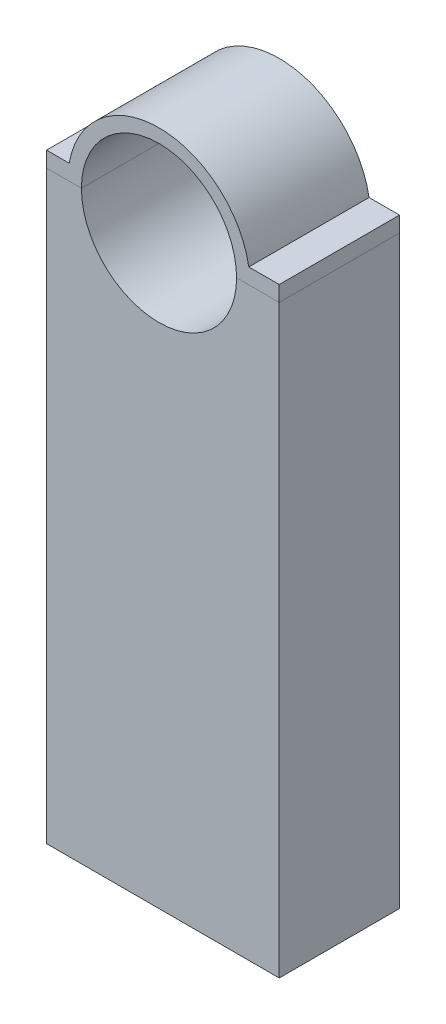
from build123d import *

# Parameters (mm, degrees)
BOSS_EXTRUDE1_DEPTH = 31
BOSS_EXTRUDE2_DEPTH = 31


with BuildPart() as part:
    # Sketch1 → Boss-Extrude1 (new body)
    with BuildSketch(Plane.XY):
        with BuildLine():
            Line((38.979674797, 141.995934959), (49.979674797, 141.995934959))
            Line((49.979674797, 141.995934959), (49.979674797, -8.844065041))
            Line((49.979674797, -8.844065041), (-10.020325203, -8.844065041))
            Line((-10.020325203, -8.844065041), (-10.020325203, 141.995934959))
            Line((-10.020325203, 141.995934959), (-1.020325203, 141.995934959))
            ThreePointArc((-1.020325203, 141.995934959), (18.979674797, 121.995934959), (38.979674797, 141.995934959))
        make_face()
    extrude(amount=BOSS_EXTRUDE1_DEPTH)


with BuildPart() as body_2:
    # Sketch2 → Boss-Extrude2 (new body)
    with BuildSketch(Plane.XY.offset(31)):
        with BuildLine():
            Line((-10.020325203, 141.995934959), (-10.020325203, 145.995934959))
            Line((-10.020325203, 145.995934959), (-4.177397557, 145.995934959))
            ThreePointArc((-4.177397557, 145.995934959), (18.979674797, 165.495934959), (42.136747151, 145.995934959))
            Line((42.136747151, 145.995934959), (49.979674797, 145.995934959))
            Line((49.979674797, 145.995934959), (49.979674797, 141.995934959))
            Line((49.979674797, 141.995934959), (38.979674797, 141.995934959))
            ThreePointArc((38.979674797, 141.995934959), (18.979674797, 161.995934959), (-1.020325203, 141.995934959))
            Line((-1.020325203, 141.995934959), (-10.020325203, 141.995934959))
        make_face()
    extrude(amount=-BOSS_EXTRUDE2_DEPTH)


solid = Compound([part.part, body_2.part])
